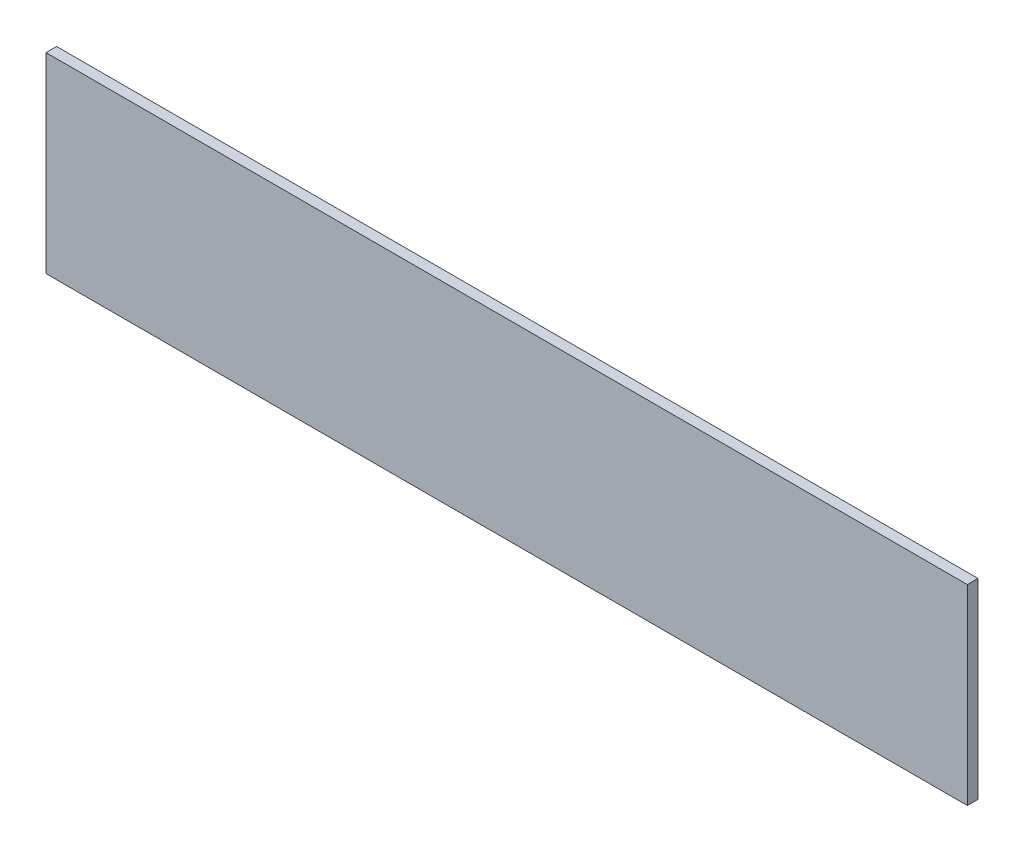
from build123d import *

# Parameters (mm, degrees)
ESBO_O1_W                = 260
ESBO_O1_H                = 54
RESSALTO_EXTRUS_O1_DEPTH = 3


with BuildPart() as part:
    # Esboço1 → Ressalto-extrusão1 (new body)
    with BuildSketch(Plane.XY):
        with Locations((130, -27)):
            Rectangle(ESBO_O1_W, ESBO_O1_H)
    extrude(amount=RESSALTO_EXTRUS_O1_DEPTH)


solid = part.part
